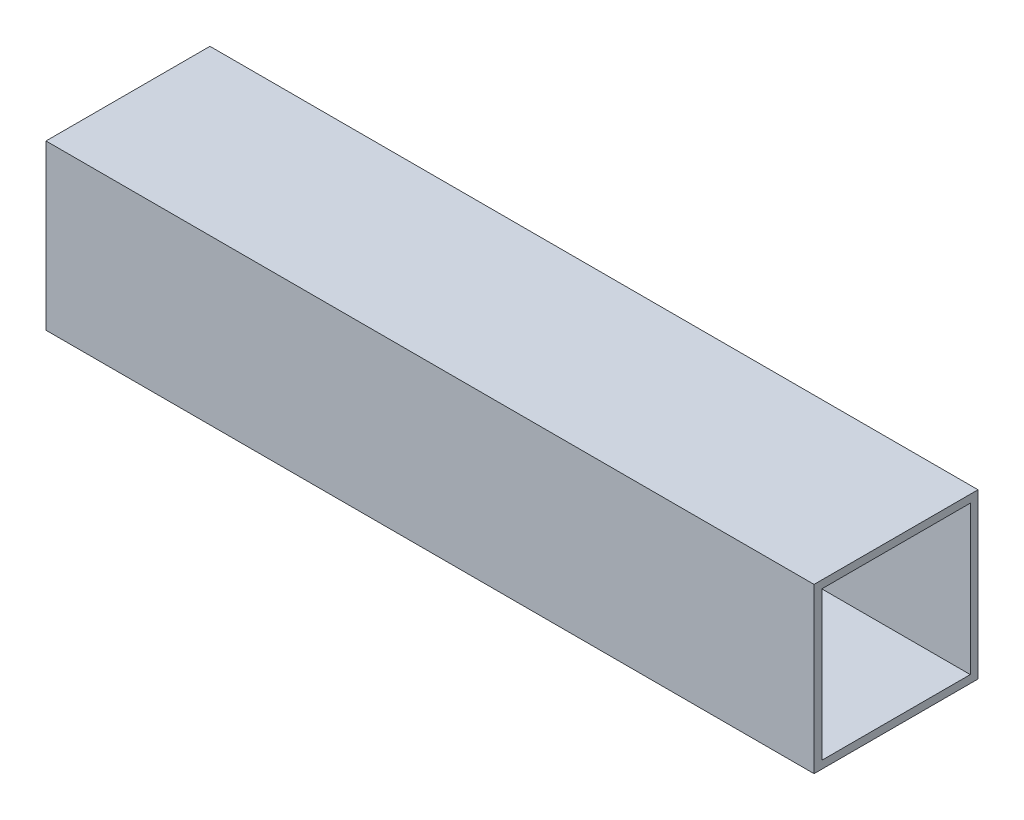
from build123d import *

# Parameters (mm, degrees)
SKETCH1_W           = 119
SKETCH1_H           = 25.4
BOSS_EXTRUDE1_DEPTH = 25.4
SKETCH2_W           = 23
SKETCH2_H           = 23
CUT_EXTRUDE1_DEPTH  = 450


with BuildPart() as part:
    # Sketch1 → Boss-Extrude1 (new body)
    with BuildSketch(Plane(origin=(0, 0, 0), x_dir=(1, 0, 0), z_dir=(0, 1, 0))):
        with Locations((59.5, 12.7)):
            Rectangle(SKETCH1_W, SKETCH1_H)
    extrude(amount=BOSS_EXTRUDE1_DEPTH)

    # Sketch2 → Cut-Extrude1 (cut)
    with BuildSketch(Plane(origin=(119, 0, 0), x_dir=(0, 0, -1), z_dir=(1, 0, 0))):
        with Locations((12.7, 12.7)):
            Rectangle(SKETCH2_W, SKETCH2_H)
    extrude(amount=-CUT_EXTRUDE1_DEPTH, mode=Mode.SUBTRACT)


solid = part.part
